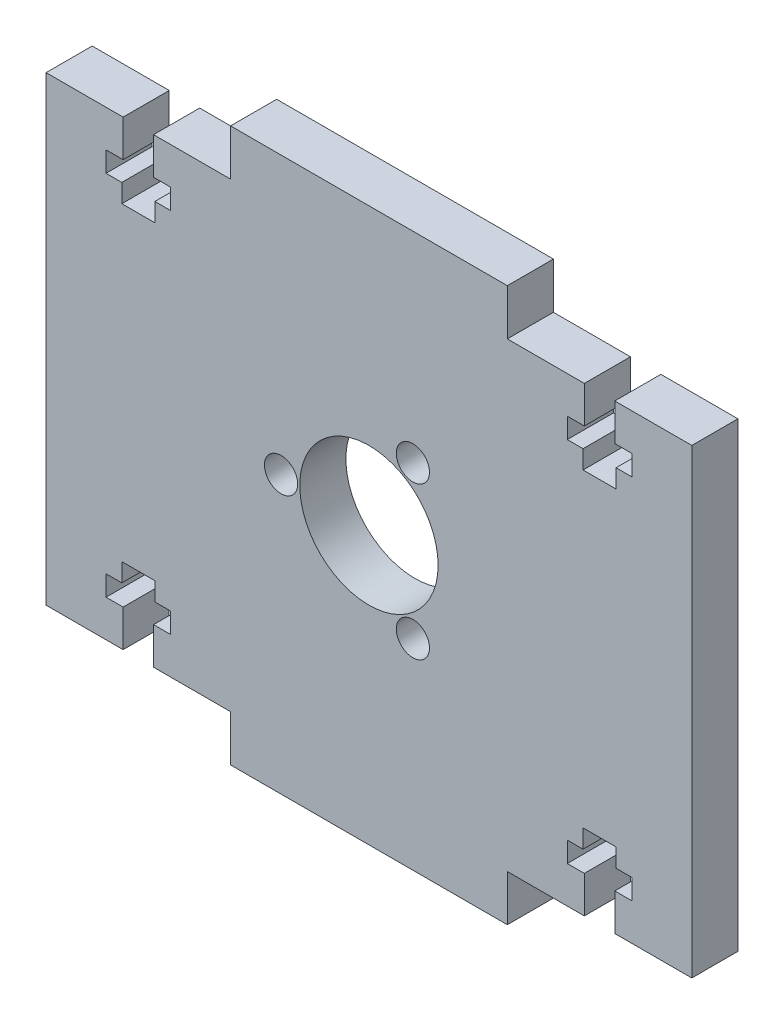
from build123d import *

# Parameters (mm, degrees)
SKETCH1_R           = 7.5
SKETCH1_R_2         = 1.8
BOSS_EXTRUDE1_DEPTH = 5
CUT_EXTRUDE1_DEPTH  = 6


with BuildPart() as part:
    # Sketch1 → Boss-Extrude1 (new body)
    with BuildSketch(Plane.XY):
        Polygon((-15, 30), (15, 30), (15, 25), (35, 25), (35, -25), (15, -25), (15, -30), (-15, -30), (-15, -25), (-35, -25), (-35, 25), (-15, 25), align=None)
        Circle(SKETCH1_R, mode=Mode.SUBTRACT)
        with Locations((4.7625, -8.248891971)):
            Circle(SKETCH1_R_2, mode=Mode.SUBTRACT)
        with Locations((-9.525, 0)):
            Circle(SKETCH1_R_2, mode=Mode.SUBTRACT)
        with Locations((4.7625, 8.248891971)):
            Circle(SKETCH1_R_2, mode=Mode.SUBTRACT)
    extrude(amount=BOSS_EXTRUDE1_DEPTH)

    # Sketch3 → Cut-Extrude1 (cut, through all)
    with BuildSketch(Plane.XY.offset(5)):
        Polygon((26.65, 25), (26.65, 21), (28.5, 21), (28.5, 18.8), (26.78859304, 18.8), (26.78859304, 16.8), (23.21140696, 16.8), (23.21140696, 18.8), (21.5, 18.8), (21.5, 21), (23.35, 21), (23.35, 25), align=None)
        Polygon((-23.35, 25), (-23.35, 21), (-21.5, 21), (-21.5, 18.8), (-23.21140696, 18.8), (-23.21140696, 16.8), (-26.78859304, 16.8), (-26.78859304, 18.8), (-28.5, 18.8), (-28.5, 21), (-26.65, 21), (-26.65, 25), align=None)
        Polygon((-26.65, -25), (-26.65, -21), (-28.5, -21), (-28.5, -18.8), (-26.78859304, -18.8), (-26.78859304, -16.8), (-23.21140696, -16.8), (-23.21140696, -18.8), (-21.5, -18.8), (-21.5, -21), (-23.35, -21), (-23.35, -25), align=None)
        Polygon((23.35, -25), (23.35, -21), (21.5, -21), (21.5, -18.8), (23.21140696, -18.8), (23.21140696, -16.8), (26.78859304, -16.8), (26.78859304, -18.8), (28.5, -18.8), (28.5, -21), (26.65, -21), (26.65, -25), align=None)
    extrude(amount=-CUT_EXTRUDE1_DEPTH, mode=Mode.SUBTRACT)


solid = part.part
